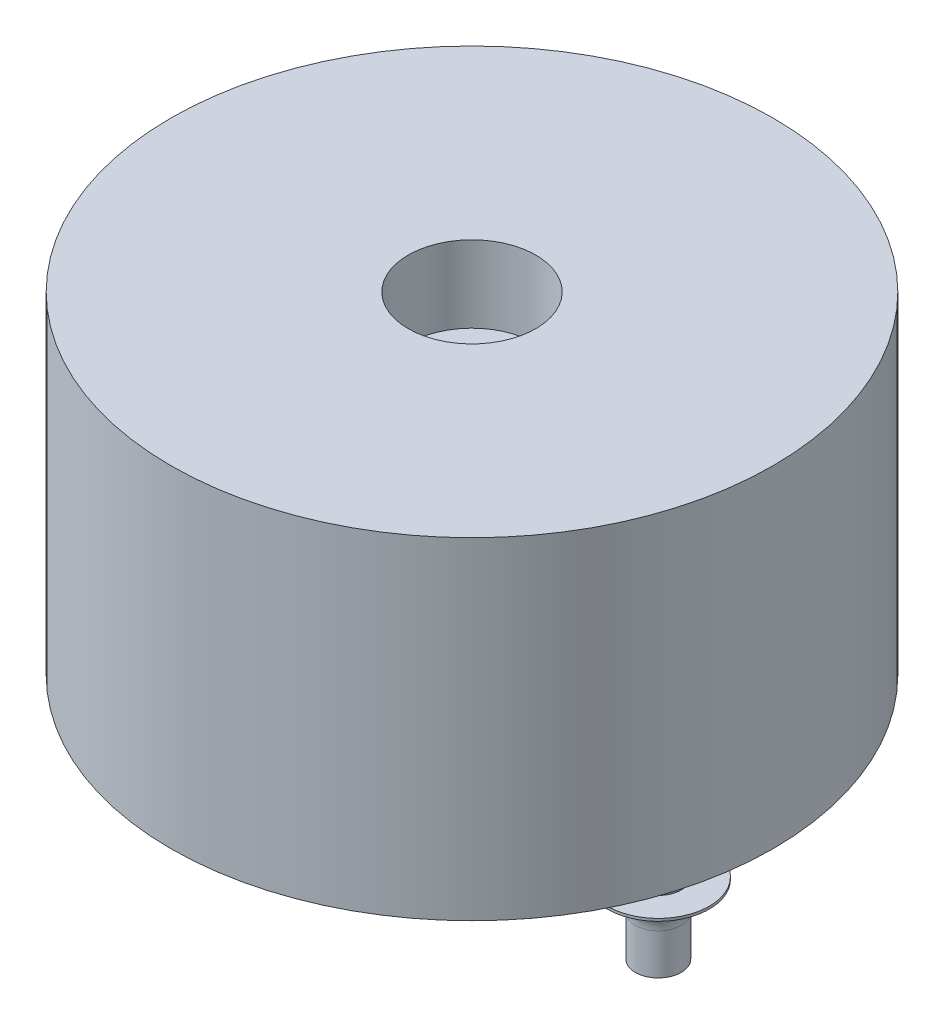
from build123d import *

# Parameters (mm, degrees)
ESQUISSE1_R                = 5.9
BOSS_EXTRU_1_DEPTH         = 6.5
ESQUISSE2_R                = 1.25
ENL_V_MAT_EXTRU_1_DEPTH    = 1.5
R_P_TITION_LIN_AIRE1_COUNT = 2
R_P_TITION_LIN_AIRE1_PITCH = 7.3


with BuildPart() as part:
    # Esquisse1 → Boss.-Extru.1 (new body)
    with BuildSketch(Plane(origin=(0, 0, 0), x_dir=(1, 0, 0), z_dir=(0, 1, 0))):
        with Locations(Location((0, 0, 0), (0, 0, 270))):  # turned: the seam where the file's is
            Circle(ESQUISSE1_R)
    extrude(amount=BOSS_EXTRU_1_DEPTH)

    # Esquisse2 → Enlèv. mat.-Extru.1 (cut)
    with BuildSketch(Plane(origin=(0, 6.5, 0), x_dir=(1, 0, 0), z_dir=(0, 1, 0))):
        with Locations(Location((0, 0, 0), (0, 0, 270))):  # turned: the seam where the file's is
            Circle(ESQUISSE2_R)
    extrude(amount=-ENL_V_MAT_EXTRU_1_DEPTH, mode=Mode.SUBTRACT)

    # Esquisse4 → Révolution1 (revolve)
    with BuildSketch(Plane.XY):
        with BuildLine():
            Line((-3.65, -3), (-4.1, -3))
            Line((-4.1, -3), (-4.1, -2.2))
            ThreePointArc((-4.1, -2.2), (-4.26109127, -1.81109127), (-4.65, -1.65))
            Line((-4.65, -1.65), (-4.65, -1.6))
            Line((-4.65, -1.6), (-4.1, -1.6))
            Line((-4.1, -1.6), (-4.1, 0))
            Line((-4.1, 0), (-3.65, 0))
            Line((-3.65, 0), (-3.65, -3))
        make_face()
    r_volution1 = revolve(axis=Axis((-3.65, 0, 0), (0, -1, 0)))

    # Répétition linéaire1: Révolution1 ×2
    with Locations(*[(i * R_P_TITION_LIN_AIRE1_PITCH, 0, 0) for i in range(1, R_P_TITION_LIN_AIRE1_COUNT)]):
        add(r_volution1)


solid = part.part
